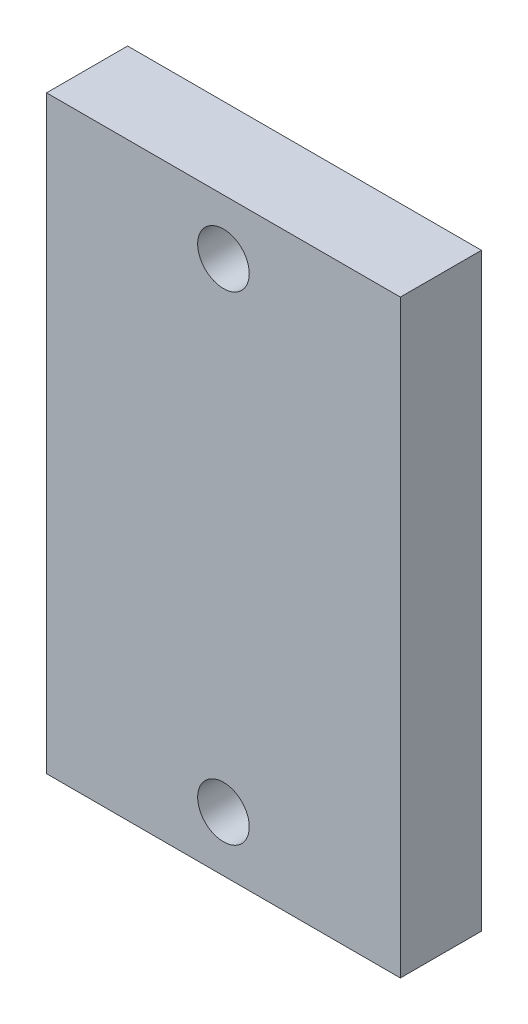
from build123d import *

# Parameters (mm, degrees)
CROQUIS1_W              = 24
CROQUIS1_H              = 40
CROQUIS1_R              = 1.75
SALIENTE_EXTRUIR1_DEPTH = 5.5


with BuildPart() as part:
    # Croquis1 → Saliente-Extruir1 (new body)
    with BuildSketch(Plane.XY):
        Rectangle(CROQUIS1_W, CROQUIS1_H)
        with Locations((0, 16.25)):
            Circle(CROQUIS1_R, mode=Mode.SUBTRACT)
        with Locations((0, -16.25)):
            Circle(CROQUIS1_R, mode=Mode.SUBTRACT)
    extrude(amount=SALIENTE_EXTRUIR1_DEPTH)


solid = part.part
